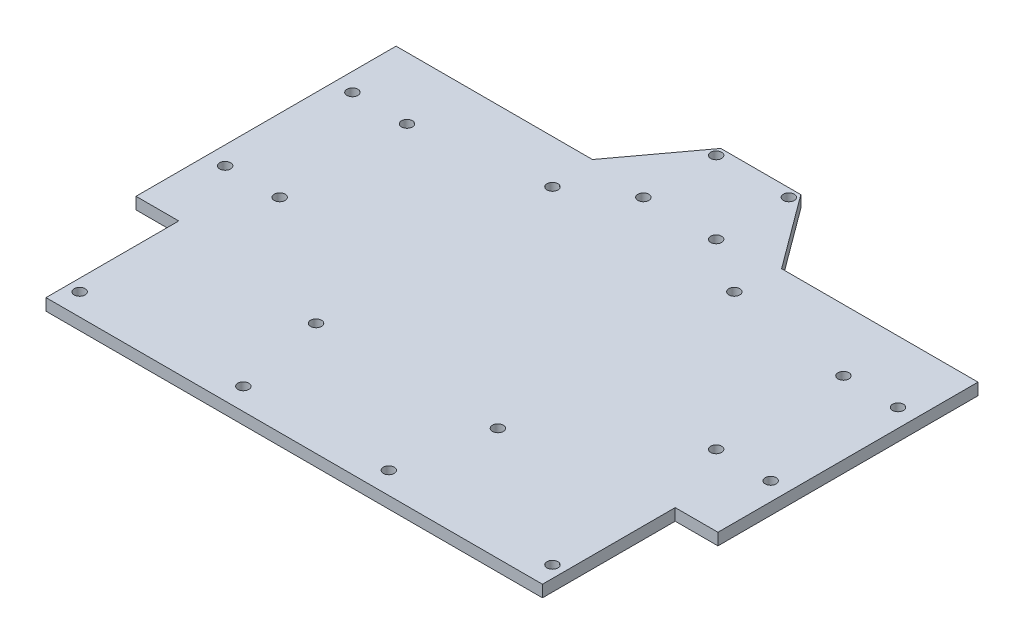
from build123d import *

# Parameters (mm, degrees)
SKETCH1_R           = 1.5025
BOSS_EXTRUDE1_DEPTH = 3.25


with BuildPart() as part:
    # Sketch1 → Boss-Extrude1 (new body)
    with BuildSketch(Plane(origin=(0, 0, 0), x_dir=(1, 0, 0), z_dir=(0, 1, 0))):
        Polygon((-11, 56.036176716), (11, 56.036176716), (26, 35.75), (80, 35.75), (80, -35.75), (68.25, -35.75), (68.25, -72.25), (-68.25, -72.25), (-68.25, -35.75), (-80, -35.75), (-80, 35.75), (-26, 35.75), align=None)
        with Locations((-10, 33.75)):
            Circle(SKETCH1_R, mode=Mode.SUBTRACT)
        with Locations((10, 33.75)):
            Circle(SKETCH1_R, mode=Mode.SUBTRACT)
        with Locations((-10, 53.75)):
            Circle(SKETCH1_R, mode=Mode.SUBTRACT)
        with Locations((10, 53.75)):
            Circle(SKETCH1_R, mode=Mode.SUBTRACT)
        with Locations((-25, 23.75)):
            Circle(SKETCH1_R, mode=Mode.SUBTRACT)
        with Locations((25, 23.75)):
            Circle(SKETCH1_R, mode=Mode.SUBTRACT)
        with Locations((-60, 18.75)):
            Circle(SKETCH1_R, mode=Mode.SUBTRACT)
        with Locations((60, 18.75)):
            Circle(SKETCH1_R, mode=Mode.SUBTRACT)
        with Locations((75, 18.75)):
            Circle(SKETCH1_R, mode=Mode.SUBTRACT)
        with Locations((-60, -16.25)):
            Circle(SKETCH1_R, mode=Mode.SUBTRACT)
        with Locations((60, -16.25)):
            Circle(SKETCH1_R, mode=Mode.SUBTRACT)
        with Locations((75, -16.25)):
            Circle(SKETCH1_R, mode=Mode.SUBTRACT)
        with Locations((-25, -41.25)):
            Circle(SKETCH1_R, mode=Mode.SUBTRACT)
        with Locations((25, -41.25)):
            Circle(SKETCH1_R, mode=Mode.SUBTRACT)
        with Locations((-65, -66.25)):
            Circle(SKETCH1_R, mode=Mode.SUBTRACT)
        with Locations((-20, -66.25)):
            Circle(SKETCH1_R, mode=Mode.SUBTRACT)
        with Locations((20, -66.25)):
            Circle(SKETCH1_R, mode=Mode.SUBTRACT)
        with Locations((65, -66.25)):
            Circle(SKETCH1_R, mode=Mode.SUBTRACT)
        with Locations((-75, 18.75)):
            Circle(SKETCH1_R, mode=Mode.SUBTRACT)
        with Locations((-75, -16.25)):
            Circle(SKETCH1_R, mode=Mode.SUBTRACT)
    extrude(amount=BOSS_EXTRUDE1_DEPTH)


solid = part.part
